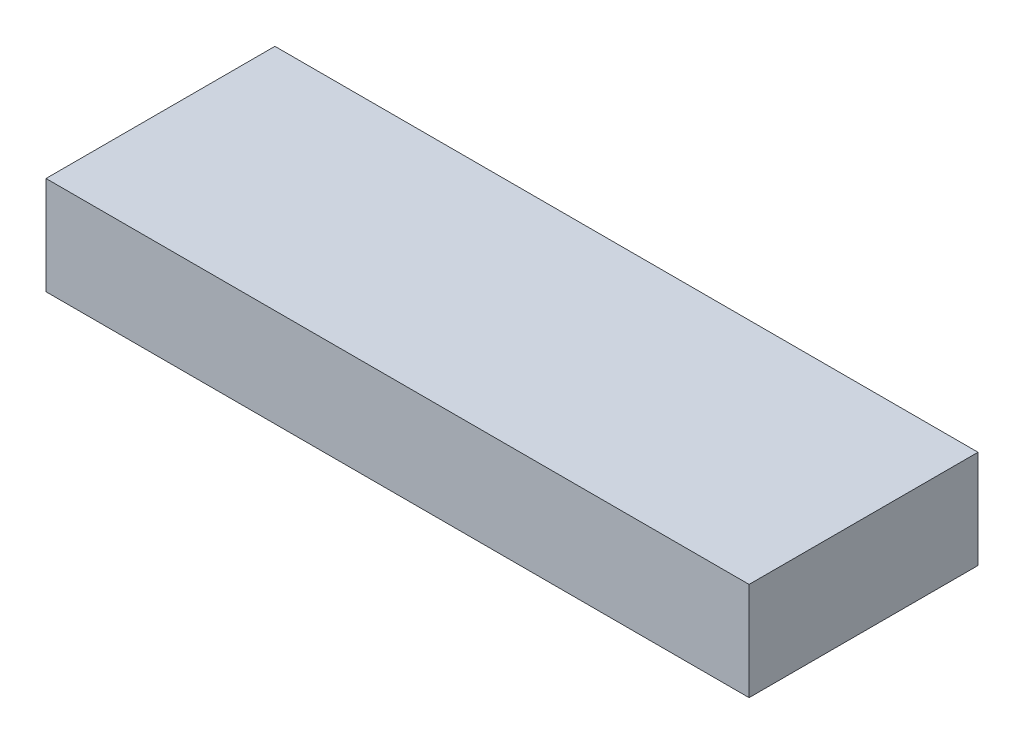
from build123d import *

# Parameters (mm, degrees)
SKETCH1_W           = 273.05
SKETCH1_H           = 88.9
BOSS_EXTRUDE1_DEPTH = 38.1


with BuildPart() as part:
    # Sketch1 → Boss-Extrude1 (new body)
    with BuildSketch(Plane(origin=(0, 0, 0), x_dir=(1, 0, 0), z_dir=(0, 1, 0))):
        with Locations((136.525, -44.45)):
            Rectangle(SKETCH1_W, SKETCH1_H)
    extrude(amount=BOSS_EXTRUDE1_DEPTH)


solid = part.part
